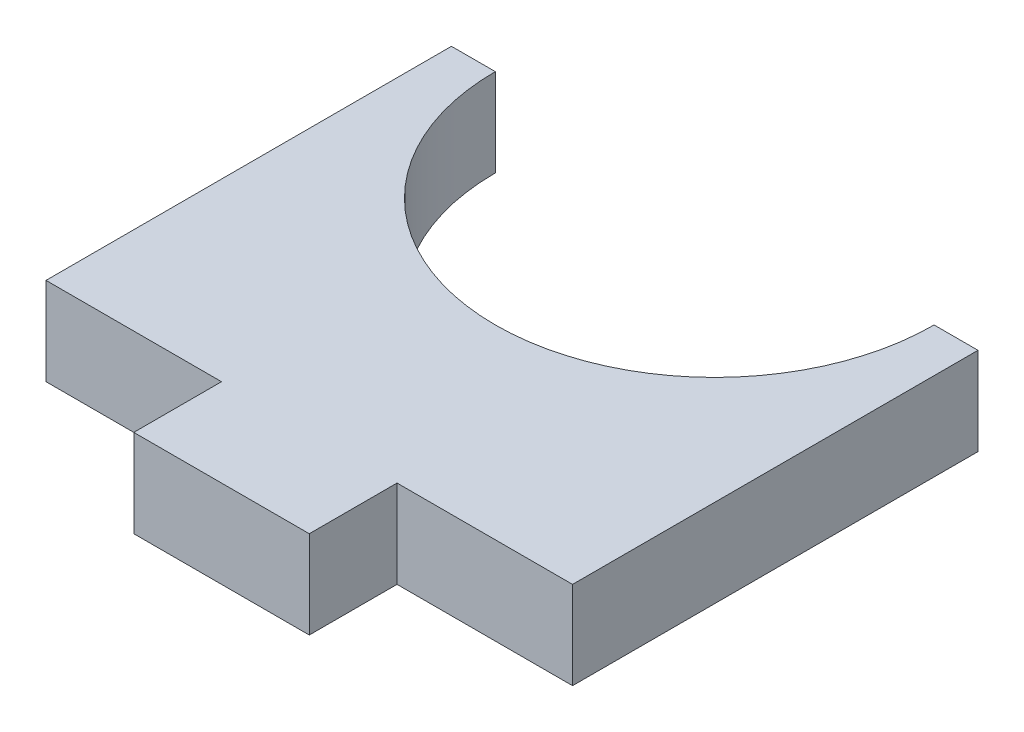
from build123d import *

# Parameters (mm, degrees)
EXTRUDE_1_DEPTH     = 5
SKETCH_2_R          = 12.5
SKETCH_2_R_2        = 1.5
SKETCH_2_R_3        = 4
EXTRUDE_2_DEPTH     = 5
SKETCH_3_W          = 10
SKETCH_3_H          = 5
EXTRUDE_3_DEPTH     = 5
CUT_EXTRUDE_1_DEPTH = 10


with BuildPart() as part:
    # 草图1 → 凸台-拉伸1 (new body)
    with BuildSketch(Plane(origin=(0, 0, 0), x_dir=(1, 0, 0), z_dir=(0, 1, 0))):
        with BuildLine():
            ThreePointArc((15, 11.55), (0, 26.55), (-15, 11.55))
            Line((-15, 11.55), (-12.5, 11.55))
            ThreePointArc((-12.5, 11.55), (0, 24.05), (12.5, 11.55))
            Line((12.5, 11.55), (15, 11.55))
        make_face()
        with BuildLine():
            Line((-12.5, 11.55), (-15, 11.55))
            ThreePointArc((-15, 11.55), (0, -3.45), (15, 11.55))
            Line((15, 11.55), (12.5, 11.55))
            ThreePointArc((12.5, 11.55), (0, -0.95), (-12.5, 11.55))
        make_face()
        with BuildLine():
            ThreePointArc((15, 11.55), (0, 26.55), (-15, 11.55))
            Line((-15, 11.55), (-12.5, 11.55))
            ThreePointArc((-12.5, 11.55), (0, 24.05), (12.5, 11.55))
            Line((12.5, 11.55), (15, 11.55))
        make_face()
        with BuildLine():
            Line((-12.5, 11.55), (-15, 11.55))
            ThreePointArc((-15, 11.55), (0, -3.45), (15, 11.55))
            Line((15, 11.55), (12.5, 11.55))
            ThreePointArc((12.5, 11.55), (0, -0.95), (-12.5, 11.55))
        make_face()
        with BuildLine():
            Line((-15, 11.55), (-15, -11.55))
            Line((-15, -11.55), (15, -11.55))
            Line((15, -11.55), (15, 11.55))
            ThreePointArc((15, 11.55), (0, -3.45), (-15, 11.55))
        make_face()
    extrude(amount=EXTRUDE_1_DEPTH)

    # 草图2 → 凸台-拉伸2 (add)
    with BuildSketch(Plane(origin=(0, 5, 0), x_dir=(1, 0, 0), z_dir=(0, 1, 0))):
        with Locations((0, 11.55)):
            Circle(SKETCH_2_R)
        with Locations((-8.5, 11.55)):
            Circle(SKETCH_2_R_2, mode=Mode.SUBTRACT)
        with Locations((8.5, 11.55)):
            Circle(SKETCH_2_R_2, mode=Mode.SUBTRACT)
        with Locations((0, 11.55)):
            Circle(SKETCH_2_R_3, mode=Mode.SUBTRACT)
    extrude(amount=-EXTRUDE_2_DEPTH)

    # 草图3 → 凸台-拉伸3 (add)
    with BuildSketch(Plane(origin=(0, 5, 0), x_dir=(1, 0, 0), z_dir=(0, 1, 0))):
        with Locations((0, -14.05)):
            Rectangle(SKETCH_3_W, SKETCH_3_H)
    extrude(amount=-EXTRUDE_3_DEPTH)

    # 草图4 → 切除-拉伸1 (cut)
    with BuildSketch(Plane(origin=(0, 5, 0), x_dir=(1, 0, 0), z_dir=(0, 1, 0))):
        with BuildLine():
            ThreePointArc((15, 11.55), (0, 26.55), (-15, 11.55))
            Line((-15, 11.55), (-12.5, 11.55))
            ThreePointArc((-12.5, 11.55), (0, 24.05), (12.5, 11.55))
            Line((12.5, 11.55), (15, 11.55))
        make_face()
        with BuildLine():
            ThreePointArc((12.5, 11.55), (0, 24.05), (-12.5, 11.55))
            Line((-12.5, 11.55), (-10, 11.55))
            ThreePointArc((-10, 11.55), (-8.5, 13.05), (-7, 11.55))
            Line((-7, 11.55), (-4, 11.55))
            ThreePointArc((-4, 11.55), (0, 15.55), (4, 11.55))
            Line((4, 11.55), (7, 11.55))
            ThreePointArc((7, 11.55), (8.5, 13.05), (10, 11.55))
            Line((10, 11.55), (12.5, 11.55))
        make_face()
        with BuildLine():
            Line((-10, 11.55), (-12.5, 11.55))
            ThreePointArc((-12.5, 11.55), (0, -0.95), (12.5, 11.55))
            Line((12.5, 11.55), (10, 11.55))
            ThreePointArc((10, 11.55), (8.5, 10.05), (7, 11.55))
            Line((7, 11.55), (4, 11.55))
            ThreePointArc((4, 11.55), (0, 7.55), (-4, 11.55))
            Line((-4, 11.55), (-7, 11.55))
            ThreePointArc((-7, 11.55), (-8.5, 10.05), (-10, 11.55))
        make_face()
        with BuildLine():
            ThreePointArc((12.5, 11.55), (0, 24.05), (-12.5, 11.55))
            Line((-12.5, 11.55), (-10, 11.55))
            ThreePointArc((-10, 11.55), (-8.5, 13.05), (-7, 11.55))
            Line((-7, 11.55), (-4, 11.55))
            ThreePointArc((-4, 11.55), (0, 15.55), (4, 11.55))
            Line((4, 11.55), (7, 11.55))
            ThreePointArc((7, 11.55), (8.5, 13.05), (10, 11.55))
            Line((10, 11.55), (12.5, 11.55))
        make_face()
        with BuildLine():
            Line((-10, 11.55), (-12.5, 11.55))
            ThreePointArc((-12.5, 11.55), (0, -0.95), (12.5, 11.55))
            Line((12.5, 11.55), (10, 11.55))
            ThreePointArc((10, 11.55), (8.5, 10.05), (7, 11.55))
            Line((7, 11.55), (4, 11.55))
            ThreePointArc((4, 11.55), (0, 7.55), (-4, 11.55))
            Line((-4, 11.55), (-7, 11.55))
            ThreePointArc((-7, 11.55), (-8.5, 10.05), (-10, 11.55))
        make_face()
    extrude(amount=-CUT_EXTRUDE_1_DEPTH, mode=Mode.SUBTRACT)


solid = part.part
